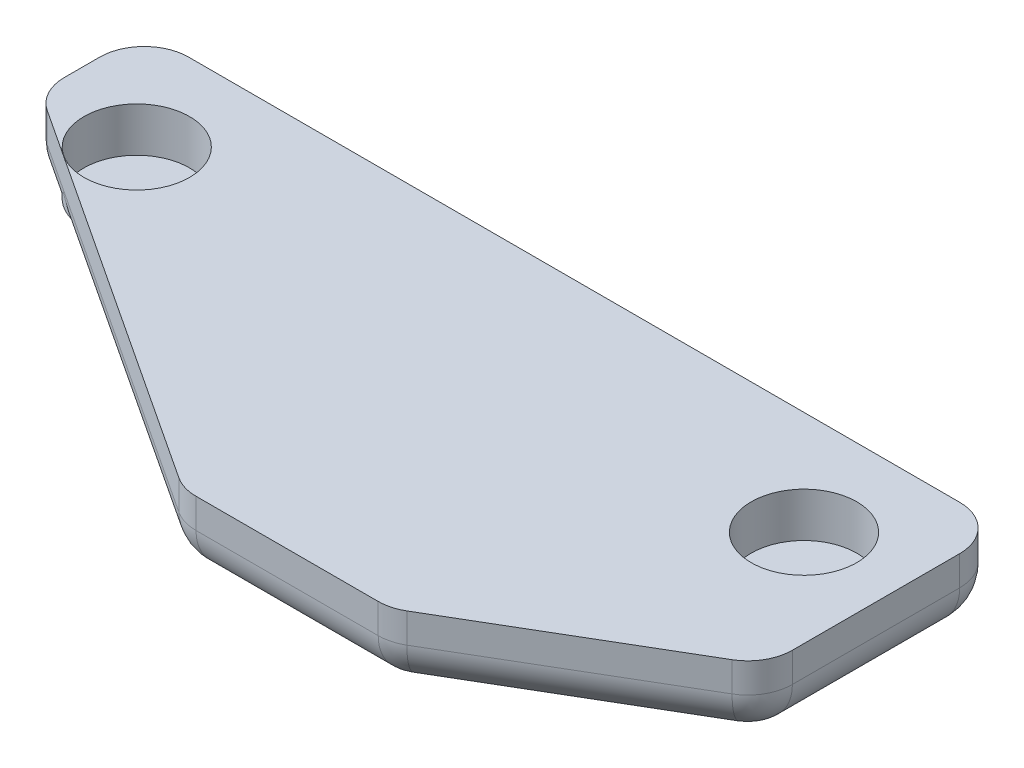
from build123d import *

# Parameters (mm, degrees)
BOSS_EXTRUDE1_DEPTH = 2.5
SKETCH4_R           = 1.78
CUT_EXTRUDE1_DEPTH  = 1.5
FILLET1_R           = 1.5


with BuildPart() as part:
    # Sketch2 → Boss-Extrude1 (new body)
    with BuildSketch(Plane(origin=(0, 0, 0), x_dir=(1, 0, 0), z_dir=(0, 1, 0))):
        Polygon((-21.216153836, 11.741903429), (-21.216153836, 8.241903429), (-7.216153836, -0.958096571), (-0.216153836, -0.958096571), (7.783846164, 3.741903429), (7.783846164, 11.741903429), align=None)
    extrude(amount=BOSS_EXTRUDE1_DEPTH)

    # Sketch4 → Cut-Extrude1 (cut)
    with BuildSketch(Plane(origin=(0, 2.5, 0), x_dir=(1, 0, 0), z_dir=(0, 1, 0))):
        with Locations((-17.966153836, 8.241903429)):
            Circle(SKETCH4_R)
        with Locations((4.533846164, 8.241903429)):
            Circle(SKETCH4_R)
    extrude(amount=-CUT_EXTRUDE1_DEPTH, mode=Mode.SUBTRACT)

    # Fillet1
    fillet1_edges = [part.edges().sort_by_distance(p)[0] for p in [
        (7.783846164, 1.25, -11.741903429),
        (7.783846164, 1.25, -3.741903429),
        (-0.216153836, 1.25, 0.958096571),
        (-7.216153836, 1.25, 0.958096571),
        (-21.216153836, 1.25, -8.241903429),
        (-21.216153836, 1.25, -11.741903429),
        (7.783846164, 0, -7.741903429),
        (3.783846164, 0, -1.391903429),
        (-3.716153836, 0, 0.958096571),
        (-14.216153836, 0, -3.641903429),
        (-21.216153836, 0, -9.991903429),
        (-6.716153836, 0, -11.741903429),
    ]]
    fillet(fillet1_edges, radius=FILLET1_R)


solid = part.part
